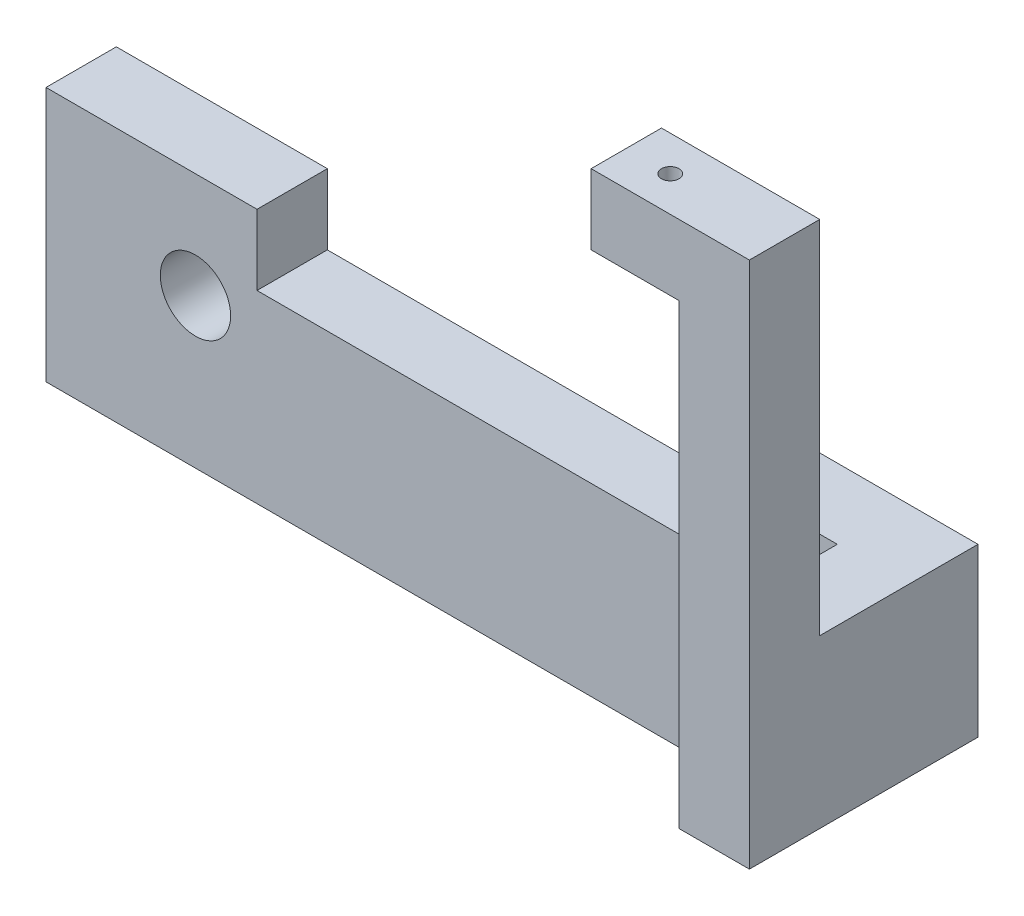
from build123d import *

# Parameters (mm, degrees)
SKETCH1_R           = 2
BOSS_EXTRUDE1_DEPTH = 13
CUT_EXTRUDE2_DEPTH  = 9
CUT_EXTRUDE3_DEPTH  = 9
SKETCH7_R           = 0.5
CUT_EXTRUDE4_DEPTH  = 4


with BuildPart() as part:
    # Sketch1 → Boss-Extrude1 (new body)
    with BuildSketch(Plane.XY):
        Polygon((-96, 0), (-54.120862841, 0), (-54.120862841, 5), (-47, 5), (-47, 14.5), (-47, 35), (-51, 35), (-56, 35), (-56, 31), (-51, 31), (-51, 14.5), (-59, 14.5), (-59, 10.5), (-84, 10.5), (-84, 14.5), (-96, 14.5), align=None)
        with Locations((-87.5, 8.5)):
            Circle(SKETCH1_R, mode=Mode.SUBTRACT)
        with Locations((-55.5, 8.5)):
            Circle(SKETCH1_R, mode=Mode.SUBTRACT)
    extrude(amount=BOSS_EXTRUDE1_DEPTH)

    # Sketch5 → Cut-Extrude2 (cut)
    with BuildSketch(Plane.XY.offset(13)):
        Polygon((-84, 14.5), (-96, 14.5), (-96, 0), (-54.120862841, 0), (-54.120862841, 5), (-51, 5), (-51, 14.5), (-59, 14.5), (-59, 10.5), (-84, 10.5), align=None)
    extrude(amount=-CUT_EXTRUDE2_DEPTH, mode=Mode.SUBTRACT)

    # Sketch6 → Cut-Extrude3 (cut)
    with BuildSketch(Plane(origin=(0, 0, 0), x_dir=(-1, 0, 0), z_dir=(0, 0, -1))):
        Polygon((51, 31), (56, 31), (56, 35), (47, 35), (47, 14.5), (51, 14.5), align=None)
    extrude(amount=-CUT_EXTRUDE3_DEPTH, mode=Mode.SUBTRACT)

    # Sketch7 → Cut-Extrude4 (cut)
    with BuildSketch(Plane(origin=(0, 31, 0), x_dir=(-1, 0, 0), z_dir=(0, -1, 0))):
        with Locations((53.5, -11)):
            Circle(SKETCH7_R)
    extrude(amount=-CUT_EXTRUDE4_DEPTH, mode=Mode.SUBTRACT)


solid = part.part
